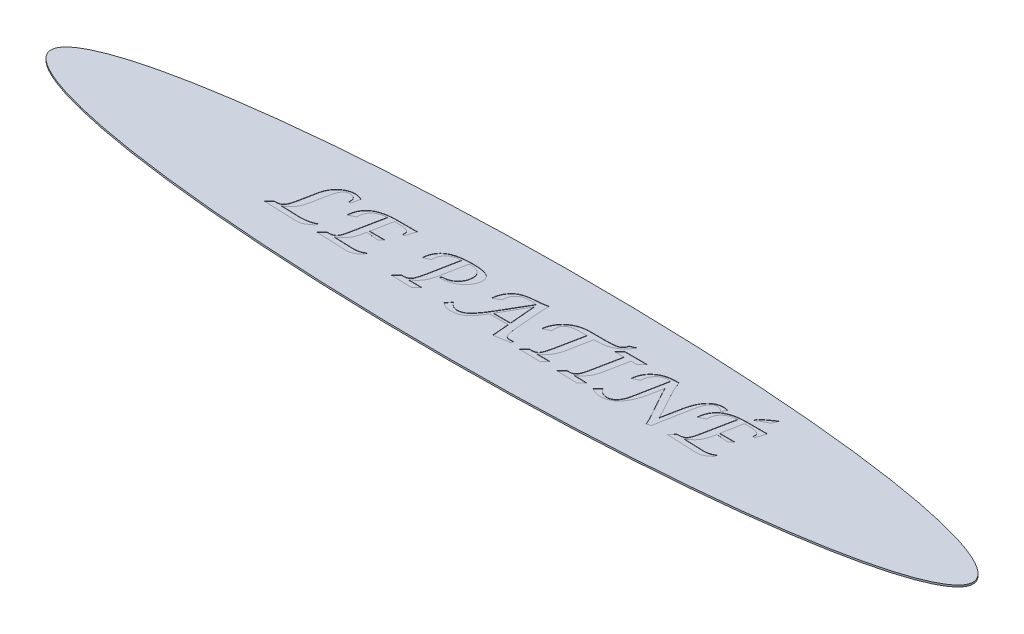
from build123d import *

# Parameters (mm, degrees)
CROQUIS1_RX             = 135
CROQUIS1_RY             = 20
SALIENTE_EXTRUIR1_DEPTH = 0.5
CORTAR_EXTRUIR2_DEPTH   = 0.1


with BuildPart() as part:
    # Croquis1 → Saliente-Extruir1 (new body)
    with BuildSketch(Plane(origin=(0, 0, 0), x_dir=(1, 0, 0), z_dir=(0, 1, 0))):
        with Locations((0, 0)):
            Ellipse(CROQUIS1_RX, CROQUIS1_RY)
    extrude(amount=SALIENTE_EXTRUIR1_DEPTH)

    # Croquis3 → Cortar-Extruir2 (cut)
    with BuildSketch(Plane(origin=(0, 0.5, 0), x_dir=(1, 0, 0), z_dir=(0, 1, 0))):
        with BuildLine():
            Line((-65.411392405, -7.111132191), (-63.984375, -5.639613203))
            Line((-63.984375, -5.639613203), (-63.399920886, -5.639613203))
            add(Edge.make_bspline(
                [(-63.399920886, -5.639613203), (-63.303900947, -5.637236771), (-63.117221766, -5.63261658), (-62.847131948, -5.599834852), (-62.596700913, -5.546924726), (-62.365912552, -5.473730418), (-62.156907433, -5.37509404), (-61.968097128, -5.254872445), (-61.796486489, -5.115429927), (-61.645744559, -4.946963441), (-61.506125109, -4.749051166), (-61.378104906, -4.512490404), (-61.24935779, -4.238829558), (-61.130395647, -3.923296605), (-61.010670602, -3.569609266), (-60.899008271, -3.17429477), (-60.793230797, -2.738452295), (-60.728083929, -2.433689909), (-60.694224684, -2.275293583)],
                knots=[0, 0, 0, 0, 0.000288021, 0.000559963, 0.000814829, 0.00105501, 0.001284604, 0.001506002, 0.001725182, 0.001945703, 0.002181948, 0.002450224, 0.002751508, 0.003088691, 0.003461148, 0.003871518, 0.004320521, 0.004806429, 0.004806429, 0.004806429, 0.004806429], degree=3))
            Line((-60.694224684, -2.275293583), (-59.667721519, 2.851288695))
            add(Edge.make_bspline(
                [(-59.667721519, 2.851288695), (-59.627267161, 3.037012829), (-59.54725351, 3.404351901), (-59.37509861, 3.936096994), (-59.171472159, 4.444476162), (-58.930105165, 4.928187917), (-58.650690184, 5.385323528), (-58.334636717, 5.818428619), (-57.979919544, 6.224883959), (-57.594112779, 6.605937947), (-57.182196709, 6.950070595), (-56.753715794, 7.253102828), (-56.308077554, 7.504965635), (-55.851693095, 7.719308113), (-55.376987269, 7.877778858), (-54.890961448, 7.995306609), (-54.390832575, 8.064440935), (-54.052818141, 8.073950173), (-53.882515823, 8.078741227)],
                knots=[0, 0, 0, 0, 0.000569937, 0.001127264, 0.001674326, 0.002211672, 0.002746942, 0.003279814, 0.003818183, 0.004363634, 0.00490493, 0.005426753, 0.005935673, 0.006438775, 0.006936954, 0.007434187, 0.007937254, 0.008448091, 0.008448091, 0.008448091, 0.008448091], degree=3))
            add(Edge.make_bspline(
                [(-53.882515823, 8.078741227), (-53.721749985, 8.071439377), (-53.383963144, 8.05609738), (-52.864124156, 7.936818748), (-52.307278396, 7.755626268), (-51.935746789, 7.586257465), (-51.740506329, 7.497253885)],
                knots=[0, 0, 0, 0, 0.000481934, 0.001012596, 0.001593334, 0.002236494, 0.002236494, 0.002236494, 0.002236494], degree=3))
            Line((-51.740506329, 7.497253885), (-52.244857595, 5.00813205))
            Line((-52.244857595, 5.00813205), (-52.888647152, 5.00813205))
            add(Edge.make_bspline(
                [(-52.888647152, 5.00813205), (-52.879568642, 5.088150387), (-52.863232465, 5.232138085), (-52.858233532, 5.37694671), (-52.856012658, 5.441280784)],
                knots=[0, 0, 0, 0, 0.000241478, 0.000434523, 0.000434523, 0.000434523, 0.000434523], degree=3))
            add(Edge.make_bspline(
                [(-52.856012658, 5.441280784), (-52.860706147, 5.58820264), (-52.869597478, 5.866530919), (-52.962190493, 6.255424091), (-53.113350494, 6.58824668), (-53.329752267, 6.861043508), (-53.609354411, 7.072030995), (-53.950905071, 7.215228007), (-54.349610684, 7.305491033), (-54.635528562, 7.314475728), (-54.787381329, 7.319247556)],
                knots=[0, 0, 0, 0, 0.000440083, 0.000833693, 0.001190717, 0.001528487, 0.001867297, 0.002229984, 0.002631585, 0.003086469, 0.003086469, 0.003086469, 0.003086469], degree=3))
            add(Edge.make_bspline(
                [(-54.787381329, 7.319247556), (-54.864657835, 7.317138052), (-55.018222737, 7.312946017), (-55.242871451, 7.274399676), (-55.457087208, 7.206762837), (-55.661538792, 7.118417153), (-55.858265269, 7.004740134), (-56.039729894, 6.85987584), (-56.218747092, 6.697110163), (-56.379779425, 6.501640208), (-56.534374584, 6.2845166), (-56.680816354, 6.043366434), (-56.813322154, 5.774486354), (-56.937767272, 5.480167133), (-57.052614513, 5.161260637), (-57.156829572, 4.81650773), (-57.251153991, 4.447129655), (-57.305151012, 4.190508393), (-57.332871835, 4.058764961)],
                knots=[0, 0, 0, 0, 0.000231712, 0.000460462, 0.000680983, 0.000904202, 0.001127578, 0.0013602, 0.0015995, 0.001852111, 0.002118014, 0.002398872, 0.002697398, 0.003016446, 0.003357109, 0.003713739, 0.004096545, 0.004500396, 0.004500396, 0.004500396, 0.004500396], degree=3))
            Line((-57.332871835, 4.058764961), (-58.258504747, -0.584233457))
            add(Edge.make_bspline(
                [(-58.258504747, -0.584233457), (-58.292898471, -0.7535984), (-58.359943319, -1.083747201), (-58.477837504, -1.56109417), (-58.61051503, -2.006151176), (-58.744164751, -2.424880304), (-58.896831163, -2.810410147), (-59.051705923, -3.168980673), (-59.222715339, -3.494279767), (-59.404237984, -3.794843203), (-59.606854625, -4.074576159), (-59.830813999, -4.343248619), (-60.080088206, -4.60336819), (-60.353821706, -4.856888021), (-60.655425792, -5.099799735), (-60.981437042, -5.337557953), (-61.335231178, -5.565333797), (-61.582676898, -5.708838614), (-61.708860759, -5.782018267)],
                knots=[0, 0, 0, 0, 0.000518439, 0.00101061, 0.001474376, 0.00191157, 0.002328631, 0.002717822, 0.003082747, 0.003430264, 0.003770319, 0.004117888, 0.004478811, 0.004850416, 0.005236382, 0.005639907, 0.006060414, 0.006497991, 0.006497991, 0.006497991, 0.006497991], degree=3))
            Line((-61.708860759, -5.782018267), (-56.086827532, -5.971891684))
            add(Edge.make_bspline(
                [(-56.086827532, -5.971891684), (-55.887971476, -5.969089823), (-55.494699148, -5.963548658), (-54.914301421, -5.918154108), (-54.351698654, -5.844352854), (-53.808631487, -5.741132748), (-53.283670301, -5.606729736), (-52.777080884, -5.444234094), (-52.287754671, -5.252207658), (-51.975876218, -5.098865286), (-51.820609177, -5.022524596)],
                knots=[0, 0, 0, 0, 0.000596506, 0.001179693, 0.001745297, 0.002298057, 0.002837006, 0.00336992, 0.003893293, 0.004412172, 0.004412172, 0.004412172, 0.004412172], degree=3))
            Line((-51.820609177, -5.022524596), (-51.971914557, -5.782018267))
            add(Edge.make_bspline(
                [(-51.971914557, -5.782018267), (-52.085315144, -5.869475741), (-52.303968469, -6.038106856), (-52.624355542, -6.274212768), (-52.9202023, -6.489494573), (-53.196847373, -6.676593474), (-53.451549976, -6.839013756), (-53.682264732, -6.980727276), (-53.893214207, -7.09261685), (-54.148454038, -7.216963911), (-54.484928401, -7.331173063), (-54.928206465, -7.423176323), (-55.427541375, -7.483744789), (-55.780066683, -7.488422565), (-55.965189873, -7.490879026)],
                knots=[0, 0, 0, 0, 0.000429609, 0.00082835, 0.001193926, 0.001527183, 0.001830041, 0.002100212, 0.002339125, 0.002546141, 0.002951472, 0.003400701, 0.003902638, 0.00445771, 0.00445771, 0.00445771, 0.00445771], degree=3))
            Line((-55.965189873, -7.490879026), (-65.411392405, -7.111132191))
        make_face()
        with BuildLine():
            Line((-49.841772152, -7.301005608), (-48.358386076, -5.793885355))
            Line((-48.358386076, -5.793885355), (-48.189280063, -5.793885355))
            add(Edge.make_bspline(
                [(-48.189280063, -5.793885355), (-48.066589336, -5.792571706), (-47.831687619, -5.790056615), (-47.49356723, -5.760179244), (-47.186168152, -5.71051009), (-46.906671513, -5.643017038), (-46.657711735, -5.555135576), (-46.437231245, -5.447301059), (-46.245157368, -5.32115011), (-46.081521014, -5.165082067), (-45.935133438, -4.977130256), (-45.799774763, -4.746015517), (-45.670898067, -4.467854302), (-45.54322036, -4.14418666), (-45.424165493, -3.772664823), (-45.304185355, -3.355686574), (-45.192890332, -2.891145907), (-45.126540853, -2.564277098), (-45.091969937, -2.393964469)],
                knots=[0, 0, 0, 0, 0.000367987, 0.000704543, 0.001017182, 0.001301404, 0.00156603, 0.001807508, 0.002036257, 0.002252425, 0.002482708, 0.00274881, 0.003054041, 0.003401673, 0.003791959, 0.004223927, 0.00470316, 0.005224502, 0.005224502, 0.005224502, 0.005224502], degree=3))
            Line((-45.091969937, -2.393964469), (-43.267405063, 6.749627303))
            add(Edge.make_bspline(
                [(-43.267405063, 6.749627303), (-43.435673845, 6.746401637), (-43.764196151, 6.740103956), (-44.244399109, 6.685347553), (-44.700171351, 6.597300709), (-45.132075294, 6.472184836), (-45.540985246, 6.31344711), (-45.921573173, 6.111668304), (-46.280212059, 5.881049051), (-46.60889738, 5.612816698), (-46.907212962, 5.318848854), (-47.168930358, 4.999699327), (-47.383868062, 4.65549753), (-47.569635171, 4.294302206), (-47.707297777, 3.907821766), (-47.805295542, 3.500024837), (-47.865765459, 3.071644118), (-47.873716156, 2.77830769), (-47.877768987, 2.628780784)],
                knots=[0, 0, 0, 0, 0.000504665, 0.000985292, 0.001447851, 0.001895716, 0.002332598, 0.002761222, 0.003185833, 0.003609791, 0.004031459, 0.004440594, 0.004844707, 0.005246724, 0.005656837, 0.006072026, 0.006503342, 0.006951805, 0.006951805, 0.006951805, 0.006951805], degree=3))
            Line((-47.877768987, 2.628780784), (-47.877768987, 2.400339328))
            Line((-47.877768987, 2.400339328), (-49.821004747, 1.427238062))
            add(Edge.make_bspline(
                [(-49.821004747, 1.427238062), (-49.7952135, 1.678161891), (-49.744991379, 2.166774442), (-49.590522064, 2.869637939), (-49.38494448, 3.525356823), (-49.115030087, 4.128747248), (-48.785282721, 4.681345033), (-48.397701432, 5.183274905), (-47.948981558, 5.634366668), (-47.439291226, 6.034679706), (-46.868345581, 6.385392376), (-46.234814571, 6.688871118), (-45.536386789, 6.941849589), (-44.77598735, 7.153201235), (-43.94971224, 7.308933916), (-43.061740595, 7.42922419), (-42.108401654, 7.49530896), (-41.451834945, 7.504424201), (-41.113528481, 7.509120974)],
                knots=[0, 0, 0, 0, 0.000756207, 0.001472527, 0.002154633, 0.002814632, 0.003450629, 0.004080843, 0.004712292, 0.005354487, 0.006020558, 0.006718526, 0.007458151, 0.008246314, 0.00908358, 0.009978547, 0.010933322, 0.011948236, 0.011948236, 0.011948236, 0.011948236], degree=3))
            Line((-41.113528481, 7.509120974), (-35.221518987, 7.509120974))
            Line((-35.221518987, 7.509120974), (-36.114517405, 4.631351986))
            Line((-36.114517405, 4.631351986), (-36.743473101, 4.631351986))
            add(Edge.make_bspline(
                [(-36.743473101, 4.631351986), (-36.720521546, 4.755607113), (-36.677201989, 4.990130521), (-36.667793799, 5.228387022), (-36.663370253, 5.340410531)],
                knots=[0, 0, 0, 0, 0.000378493, 0.000714381, 0.000714381, 0.000714381, 0.000714381], degree=3))
            add(Edge.make_bspline(
                [(-36.663370253, 5.340410531), (-36.666356126, 5.404886678), (-36.672163887, 5.53029795), (-36.713270473, 5.710890762), (-36.786818947, 5.873649369), (-36.885742338, 6.023521663), (-37.019177303, 6.151942235), (-37.174832336, 6.270815335), (-37.36239494, 6.367537369), (-37.579486242, 6.450824874), (-37.833911454, 6.521965113), (-38.13143403, 6.582760109), (-38.474902538, 6.636141161), (-38.865310461, 6.674871891), (-39.301286694, 6.712073168), (-39.784200072, 6.734600318), (-40.313442067, 6.744943849), (-40.681364636, 6.748022121), (-40.873219937, 6.749627303)],
                knots=[0, 0, 0, 0, 0.00019341, 0.000376198, 0.000551514, 0.000726779, 0.000911388, 0.001104228, 0.0013126, 0.001541792, 0.001800973, 0.002104121, 0.002452385, 0.002843246, 0.003280812, 0.003764978, 0.004293197, 0.004868781, 0.004868781, 0.004868781, 0.004868781], degree=3))
            Line((-40.873219937, 6.749627303), (-41.184731013, 6.749627303))
            Line((-41.184731013, 6.749627303), (-42.347705696, 0.673677936))
            Line((-42.347705696, 0.673677936), (-37.876780063, 0.673677936))
            Line((-37.876780063, 0.673677936), (-38.900316456, -0.364692317))
            add(Edge.make_bspline(
                [(-38.900316456, -0.364692317), (-39.08225535, -0.342747119), (-39.430189054, -0.300779873), (-39.930499289, -0.243454679), (-40.385691963, -0.197683358), (-40.794711042, -0.153971771), (-41.158800961, -0.124143139), (-41.477389149, -0.104961757), (-41.751181498, -0.086632105), (-41.918488753, -0.086071133), (-41.99465981, -0.085815735)],
                knots=[0, 0, 0, 0, 0.000549774, 0.001051369, 0.001510711, 0.001922227, 0.002285388, 0.002606471, 0.002879817, 0.003108278, 0.003108278, 0.003108278, 0.003108278], degree=3))
            Line((-41.99465981, -0.085815735), (-42.496044304, -0.085815735))
            Line((-42.496044304, -0.085815735), (-42.706685127, -1.12715276))
            add(Edge.make_bspline(
                [(-42.706685127, -1.12715276), (-42.7357891, -1.269922261), (-42.792690032, -1.549049705), (-42.90235544, -1.952664757), (-43.015936881, -2.335632387), (-43.143587971, -2.695134193), (-43.283218076, -3.031859219), (-43.434365873, -3.345495989), (-43.594372115, -3.639176578), (-43.770993654, -3.911858369), (-43.96939246, -4.17179544), (-44.187625613, -4.429847991), (-44.435934178, -4.684828661), (-44.709492386, -4.941048238), (-45.0114453, -5.194372407), (-45.340761445, -5.447678767), (-45.694721004, -5.702951942), (-45.945657749, -5.865195852), (-46.073971519, -5.948157507)],
                knots=[0, 0, 0, 0, 0.000437003, 0.00085438, 0.001254202, 0.001635175, 0.001998262, 0.002347246, 0.002679206, 0.003000961, 0.003320781, 0.00365963, 0.004014218, 0.004387843, 0.00478366, 0.005196084, 0.005634083, 0.006092408, 0.006092408, 0.006092408, 0.006092408], degree=3))
            Line((-46.073971519, -5.948157507), (-41.264833861, -6.132097381))
            Line((-41.264833861, -6.132097381), (-40.211629747, -6.161765102))
            add(Edge.make_bspline(
                [(-40.211629747, -6.161765102), (-40.077018344, -6.15889603), (-39.808053803, -6.15316339), (-39.408310917, -6.107457869), (-39.01465443, -6.033100049), (-38.628627848, -5.929513707), (-38.249335267, -5.79417776), (-37.876136612, -5.631615688), (-37.509047125, -5.438348391), (-37.274485332, -5.288290571), (-37.15585443, -5.212398014)],
                knots=[0, 0, 0, 0, 0.000403754, 0.000806733, 0.001205308, 0.001604722, 0.002004455, 0.00241233, 0.002825063, 0.003247409, 0.003247409, 0.003247409, 0.003247409], degree=3))
            Line((-37.15585443, -5.212398014), (-37.316060127, -5.971891684))
            add(Edge.make_bspline(
                [(-37.316060127, -5.971891684), (-37.460524559, -6.107555889), (-37.740478859, -6.370456429), (-38.177436071, -6.716421566), (-38.604713757, -7.012381942), (-39.025110437, -7.25648344), (-39.440779699, -7.444308192), (-39.850101693, -7.579788653), (-40.253616408, -7.664678925), (-40.521765921, -7.67545251), (-40.653678797, -7.680752444)],
                knots=[0, 0, 0, 0, 0.00059431, 0.001151701, 0.001670139, 0.002152566, 0.002608031, 0.003035843, 0.003444289, 0.003839772, 0.003839772, 0.003839772, 0.003839772], degree=3))
            Line((-40.653678797, -7.680752444), (-41.113528481, -7.671852127))
            Line((-41.113528481, -7.671852127), (-49.841772152, -7.301005608))
        make_face()
        with BuildLine():
            Line((-28.006329114, -7.301005608), (-26.534810127, -5.782018267))
            Line((-26.534810127, -5.782018267), (-26.347903481, -5.782018267))
            Line((-26.347903481, -5.782018267), (-25.920688291, -5.77311795))
            add(Edge.make_bspline(
                [(-25.920688291, -5.77311795), (-25.826555496, -5.771414478), (-25.64435771, -5.768117338), (-25.381633574, -5.726386619), (-25.136548137, -5.670278639), (-24.912702599, -5.582825913), (-24.707288697, -5.472543387), (-24.524129178, -5.334933662), (-24.357079354, -5.176549111), (-24.212672217, -4.985456026), (-24.075531173, -4.759360586), (-23.948050272, -4.485676357), (-23.821134115, -4.163144193), (-23.693596106, -3.792166792), (-23.570774774, -3.369758838), (-23.446341019, -2.899075844), (-23.324183821, -2.377796019), (-23.250542485, -2.012461199), (-23.212025316, -1.821377444)],
                knots=[0, 0, 0, 0, 0.000282093, 0.000546002, 0.000796409, 0.001034972, 0.001264643, 0.001493681, 0.001720285, 0.001952907, 0.002209854, 0.002512406, 0.00285728, 0.003249456, 0.003688778, 0.004176675, 0.004709919, 0.005294674, 0.005294674, 0.005294674, 0.005294674], degree=3))
            Line((-23.212025316, -1.821377444), (-21.532832278, 6.749627303))
            add(Edge.make_bspline(
                [(-21.532832278, 6.749627303), (-21.698117322, 6.746152484), (-22.02058098, 6.739373268), (-22.492863118, 6.688080317), (-22.940998533, 6.603856901), (-23.365129064, 6.480052406), (-23.766935238, 6.327953542), (-24.143811647, 6.135352263), (-24.497075506, 5.910510157), (-24.822616535, 5.652521837), (-25.11748487, 5.368631821), (-25.372413264, 5.058873443), (-25.592302442, 4.729948839), (-25.771045503, 4.378609984), (-25.907606622, 4.004692489), (-26.005178287, 3.610849838), (-26.065986085, 3.196325908), (-26.07389408, 2.912812841), (-26.077927215, 2.768219075)],
                knots=[0, 0, 0, 0, 0.000495771, 0.000967226, 0.001423396, 0.001861886, 0.002291085, 0.002710356, 0.00312926, 0.003545338, 0.003954462, 0.004354834, 0.004746504, 0.00513924, 0.0055344, 0.005938067, 0.006354695, 0.006788341, 0.006788341, 0.006788341, 0.006788341], degree=3))
            Line((-26.077927215, 2.768219075), (-26.069026899, 2.548677936))
            Line((-26.069026899, 2.548677936), (-27.997428797, 1.611177936))
            add(Edge.make_bspline(
                [(-27.997428797, 1.611177936), (-27.969629807, 1.860153976), (-27.91548491, 2.345091801), (-27.755894494, 3.041372051), (-27.543426074, 3.686133461), (-27.273594004, 4.279053121), (-26.940996738, 4.816841303), (-26.553906662, 5.305306366), (-26.104868455, 5.73766668), (-25.596514248, 6.118773247), (-25.023286423, 6.449644607), (-24.380694312, 6.732977614), (-23.668962468, 6.975596172), (-22.886200884, 7.173540173), (-22.030947805, 7.321927399), (-21.105823369, 7.429255744), (-20.109874011, 7.499936763), (-19.422596314, 7.505991948), (-19.06744462, 7.509120974)],
                knots=[0, 0, 0, 0, 0.000751068, 0.001462877, 0.002138364, 0.002784855, 0.003412248, 0.004030797, 0.004649744, 0.00527692, 0.005932315, 0.006630868, 0.007380499, 0.008185682, 0.009050484, 0.009982603, 0.010978812, 0.012044085, 0.012044085, 0.012044085, 0.012044085], degree=3))
            add(Edge.make_bspline(
                [(-19.06744462, 7.509120974), (-18.812284029, 7.506413582), (-18.321563366, 7.50120677), (-17.613839806, 7.473709952), (-16.962794251, 7.419482462), (-16.368032105, 7.349211764), (-15.830947053, 7.249159922), (-15.348846664, 7.137219741), (-14.923559376, 6.998996523), (-14.552567625, 6.837617438), (-14.229346165, 6.65396599), (-13.953808328, 6.437794926), (-13.718298132, 6.195477708), (-13.52621944, 5.922068262), (-13.377554846, 5.619474451), (-13.269556977, 5.289210034), (-13.207464119, 4.93036783), (-13.200029122, 4.6820291), (-13.196202532, 4.55421591)],
                knots=[0, 0, 0, 0, 0.000765519, 0.001472234, 0.002124148, 0.002725064, 0.003267983, 0.003762332, 0.004208907, 0.004607439, 0.004974324, 0.005320916, 0.00565453, 0.005984589, 0.00631894, 0.006662318, 0.007023741, 0.007407018, 0.007407018, 0.007407018, 0.007407018], degree=3))
            add(Edge.make_bspline(
                [(-13.196202532, 4.55421591), (-13.198993684, 4.447240901), (-13.204599767, 4.232379587), (-13.252402395, 3.911178748), (-13.321931401, 3.587744813), (-13.428872116, 3.264740276), (-13.558145925, 2.93755943), (-13.720577913, 2.610222077), (-13.910113872, 2.280771267), (-14.129075076, 1.955190646), (-14.366737954, 1.635604522), (-14.625972818, 1.334797542), (-14.894989886, 1.047181655), (-15.183387324, 0.784622689), (-15.485642124, 0.539148293), (-15.801867126, 0.311165234), (-16.134361857, 0.101987263), (-16.366808482, -0.019135967), (-16.483386076, -0.079882191)],
                knots=[0, 0, 0, 0, 0.000320755, 0.000644242, 0.000972469, 0.001312109, 0.001663594, 0.002027141, 0.00240727, 0.002803054, 0.003203568, 0.003601304, 0.003993737, 0.004384293, 0.004770259, 0.005161355, 0.005553194, 0.005947429, 0.005947429, 0.005947429, 0.005947429], degree=3))
            add(Edge.make_bspline(
                [(-16.483386076, -0.079882191), (-16.621011741, -0.145089051), (-16.898441246, -0.276534787), (-17.331815215, -0.4394875), (-17.777153558, -0.584950881), (-18.239065913, -0.69553847), (-18.714318282, -0.784901375), (-19.20441844, -0.850243959), (-19.709585179, -0.889751365), (-20.051352341, -0.893729352), (-20.224485759, -0.895744533)],
                knots=[0, 0, 0, 0, 0.00045669, 0.000920608, 0.001387854, 0.001861321, 0.002344277, 0.002838126, 0.00334395, 0.003863271, 0.003863271, 0.003863271, 0.003863271], degree=3))
            Line((-20.224485759, -0.895744533), (-20.494462025, -0.895744533))
            Line((-20.494462025, -0.895744533), (-20.120648734, -0.326124279))
            Line((-20.120648734, -0.326124279), (-19.942642405, -0.326124279))
            add(Edge.make_bspline(
                [(-19.942642405, -0.326124279), (-19.787173722, -0.322123377), (-19.482002293, -0.314269955), (-19.034233103, -0.252712163), (-18.605152677, -0.156841697), (-18.196381419, -0.015130278), (-17.804885536, 0.162895915), (-17.433597847, 0.38364689), (-17.0818619, 0.643106649), (-16.754577474, 0.938787423), (-16.45584698, 1.263061656), (-16.194378657, 1.611436785), (-15.969185719, 1.977757616), (-15.787895946, 2.365150589), (-15.648554123, 2.771317708), (-15.546624992, 3.195235187), (-15.486895562, 3.639734466), (-15.478805431, 3.942881113), (-15.474683544, 4.097332999)],
                knots=[0, 0, 0, 0, 0.000466246, 0.0009152, 0.00135349, 0.001783191, 0.002210663, 0.002641622, 0.003076565, 0.003519808, 0.003962851, 0.004397187, 0.004824587, 0.005250616, 0.005677512, 0.006110701, 0.006556715, 0.007019997, 0.007019997, 0.007019997, 0.007019997], degree=3))
            add(Edge.make_bspline(
                [(-15.474683544, 4.097332999), (-15.477102871, 4.212229585), (-15.481817761, 4.436145059), (-15.530740752, 4.760246062), (-15.607082053, 5.061902456), (-15.714060037, 5.341753107), (-15.855316987, 5.598004109), (-16.024375758, 5.835325392), (-16.229411426, 6.046381544), (-16.461643474, 6.237484501), (-16.725618458, 6.404861405), (-17.022112923, 6.546721403), (-17.348394512, 6.666662934), (-17.703956519, 6.769040627), (-18.091353609, 6.843998282), (-18.509275223, 6.900531922), (-18.95817273, 6.932326219), (-19.267159412, 6.937060483), (-19.426424051, 6.939500721)],
                knots=[0, 0, 0, 0, 0.000344465, 0.000671309, 0.000980722, 0.001276582, 0.001567341, 0.001856354, 0.002148019, 0.002447355, 0.002756811, 0.003083223, 0.0034315, 0.003798673, 0.004191991, 0.004614087, 0.005063257, 0.005541054, 0.005541054, 0.005541054, 0.005541054], degree=3))
            Line((-19.426424051, 6.939500721), (-21.016613924, -1.156820482))
            add(Edge.make_bspline(
                [(-21.016613924, -1.156820482), (-21.071806858, -1.40545089), (-21.180656094, -1.895789566), (-21.43102481, -2.599171013), (-21.742922335, -3.261783175), (-22.121713117, -3.882707927), (-22.567790555, -4.460192019), (-23.073522804, -5.000908444), (-23.649994639, -5.496387003), (-24.073438144, -5.785944075), (-24.288963608, -5.933323646)],
                knots=[0, 0, 0, 0, 0.000763453, 0.00150565, 0.002234226, 0.002957249, 0.003682969, 0.004419667, 0.005174913, 0.005957792, 0.005957792, 0.005957792, 0.005957792], degree=3))
            Line((-24.288963608, -5.933323646), (-20.485561709, -5.971891684))
            Line((-20.485561709, -5.971891684), (-21.850276899, -7.490879026))
            Line((-21.850276899, -7.490879026), (-28.006329114, -7.301005608))
        make_face()
        with BuildLine():
            Line((-13.386075949, -6.541511938), (-12.056962025, -5.022524596))
            add(Edge.make_bspline(
                [(-12.056962025, -5.022524596), (-11.977570155, -5.143176153), (-11.823341857, -5.377556377), (-11.553824372, -5.686898169), (-11.268265542, -5.951154763), (-10.963357492, -6.167227143), (-10.640042966, -6.335521131), (-10.297521317, -6.455169912), (-9.935863724, -6.52841537), (-9.687843766, -6.537101421), (-9.561906646, -6.541511938)],
                knots=[0, 0, 0, 0, 0.000432874, 0.000840911, 0.001227275, 0.001597682, 0.001958606, 0.002317033, 0.002683006, 0.003060533, 0.003060533, 0.003060533, 0.003060533], degree=3))
            add(Edge.make_bspline(
                [(-9.561906646, -6.541511938), (-9.439989457, -6.538683995), (-9.196654543, -6.533039695), (-8.835394372, -6.46867514), (-8.478725111, -6.376017708), (-8.128570486, -6.239465054), (-7.783711307, -6.067094008), (-7.444581103, -5.854802871), (-7.111484283, -5.604298638), (-6.781579021, -5.311332237), (-6.445616238, -4.971483588), (-6.099615912, -4.57413838), (-5.733794348, -4.120060725), (-5.357728688, -3.603567383), (-4.960805841, -3.031632988), (-4.550011695, -2.399986558), (-4.122501141, -1.708642735), (-3.839859717, -1.223747671), (-3.693631329, -0.972880608)],
                knots=[0, 0, 0, 0, 0.000365347, 0.000729197, 0.001097651, 0.001469552, 0.001854318, 0.002252761, 0.002668109, 0.003103215, 0.00357523, 0.004100759, 0.004683169, 0.005324019, 0.006016956, 0.006771531, 0.007584151, 0.008455241, 0.008455241, 0.008455241, 0.008455241], degree=3))
            Line((-3.693631329, -0.972880608), (0.623022152, 6.467783948))
            add(Edge.make_bspline(
                [(0.623022152, 6.467783948), (0.448058791, 6.487308743), (0.111322248, 6.524886392), (-0.375252773, 6.567272698), (-0.823521351, 6.591762584), (-1.109547497, 6.596202917), (-1.246044304, 6.598321923)],
                knots=[0, 0, 0, 0, 0.000528135, 0.001016456, 0.001465067, 0.001874578, 0.001874578, 0.001874578, 0.001874578], degree=3))
            add(Edge.make_bspline(
                [(-1.246044304, 6.598321923), (-1.41523857, 6.594494893), (-1.744418951, 6.587049114), (-2.223993723, 6.541211838), (-2.672826658, 6.456689162), (-3.094138978, 6.346372793), (-3.4845721, 6.197173125), (-3.844791213, 6.015308879), (-4.178304178, 5.804631006), (-4.477538685, 5.556949163), (-4.746303328, 5.281835867), (-4.975270085, 4.974934609), (-5.174409085, 4.64468375), (-5.330169269, 4.281299453), (-5.455405614, 3.892084528), (-5.543211685, 3.474531496), (-5.597825737, 3.029759211), (-5.604014577, 2.723883079), (-5.607199367, 2.566478569)],
                knots=[0, 0, 0, 0, 0.00050763, 0.000987633, 0.001443253, 0.001876493, 0.002292487, 0.002694504, 0.00308542, 0.003473263, 0.003857216, 0.004236371, 0.004619499, 0.005011405, 0.005419538, 0.005844315, 0.006289578, 0.006761631, 0.006761631, 0.006761631, 0.006761631], degree=3))
            Line((-5.607199367, 2.566478569), (-7.568235759, 1.596344075))
            add(Edge.make_bspline(
                [(-7.568235759, 1.596344075), (-7.54982834, 1.749815783), (-7.513722375, 2.050848974), (-7.437055781, 2.492055753), (-7.336949942, 2.912214085), (-7.213344481, 3.311500911), (-7.076373697, 3.69284928), (-6.911640994, 4.051807549), (-6.729198287, 4.392169915), (-6.587949586, 4.603720839), (-6.517998418, 4.708488062)],
                knots=[0, 0, 0, 0, 0.000463662, 0.000909468, 0.001342658, 0.001758398, 0.002162935, 0.002557259, 0.002942254, 0.003319979, 0.003319979, 0.003319979, 0.003319979], degree=3))
            add(Edge.make_bspline(
                [(-6.517998418, 4.708488062), (-6.438116882, 4.819180099), (-6.280935204, 5.03698713), (-6.0276062, 5.343374212), (-5.764479386, 5.626309), (-5.487169245, 5.881163412), (-5.201789087, 6.114353371), (-4.905557738, 6.322044589), (-4.597919325, 6.504214578), (-4.275503239, 6.663541537), (-3.929645159, 6.804734427), (-3.551257329, 6.92778825), (-3.137433589, 7.040791967), (-2.687638959, 7.139826109), (-2.202106102, 7.230173299), (-1.679159786, 7.30215014), (-1.120378247, 7.365607336), (-0.734894366, 7.393784486), (-0.536985759, 7.408250721)],
                knots=[0, 0, 0, 0, 0.000409425, 0.00080562, 0.001191825, 0.001567622, 0.001934592, 0.002296733, 0.002651879, 0.003006132, 0.003374705, 0.003771554, 0.004199068, 0.004661161, 0.005152867, 0.005680261, 0.006244431, 0.006839681, 0.006839681, 0.006839681, 0.006839681], degree=3))
            add(Edge.make_bspline(
                [(-0.536985759, 7.408250721), (-0.445012477, 7.414125942), (-0.24025497, 7.427205781), (0.098094484, 7.450258014), (0.498296761, 7.484945265), (0.786169128, 7.50647923), (0.940466772, 7.51802129)],
                knots=[0, 0, 0, 0, 0.000276483, 0.000615527, 0.001017369, 0.001481553, 0.001481553, 0.001481553, 0.001481553], degree=3))
            Line((0.940466772, 7.51802129), (2.981606013, 7.888867809))
            Line((2.981606013, 7.888867809), (3.112143987, 4.551249138))
            Line((3.112143987, 4.551249138), (3.690664557, -2.373197064))
            add(Edge.make_bspline(
                [(3.690664557, -2.373197064), (3.708031573, -2.56607434), (3.74118594, -2.934285219), (3.795452341, -3.460986509), (3.861722046, -3.935471481), (3.929870328, -4.359793203), (3.997511419, -4.734094326), (4.079092592, -5.055160333), (4.159241515, -5.325959659), (4.248513816, -5.549847834), (4.35338978, -5.734598446), (4.470867293, -5.89339105), (4.609895952, -6.025997364), (4.767395489, -6.13431087), (4.941885369, -6.220659385), (5.136275987, -6.279937581), (5.347753699, -6.315754251), (5.495302141, -6.319851927), (5.571598101, -6.321970798)],
                knots=[0, 0, 0, 0, 0.00058098, 0.001109115, 0.001588265, 0.002017966, 0.0023985, 0.002728773, 0.00301124, 0.00324539, 0.003449989, 0.003646984, 0.003835835, 0.00402347, 0.004218511, 0.00441744, 0.004631068, 0.004859817, 0.004859817, 0.004859817, 0.004859817], degree=3))
            add(Edge.make_bspline(
                [(5.571598101, -6.321970798), (5.590389528, -6.322103843), (5.63590287, -6.322426082), (5.717017235, -6.318824886), (5.823719407, -6.312050221), (5.957344091, -6.307433885), (6.116439442, -6.297159594), (6.301480967, -6.289446528), (6.512103259, -6.277100981), (6.661396829, -6.267645658), (6.740506329, -6.262635355)],
                knots=[0, 0, 0, 0, 5.6369e-05, 0.000136526, 0.000243495, 0.000377131, 0.000537584, 0.000721739, 0.000932714, 0.001170519, 0.001170519, 0.001170519, 0.001170519], degree=3))
            Line((6.740506329, -6.262635355), (6.740506329, -6.921258773))
            Line((6.740506329, -6.921258773), (2.020371835, -7.680752444))
            Line((2.020371835, -7.680752444), (1.610957278, -2.744043583))
            Line((1.610957278, -2.744043583), (-3.839003165, -2.744043583))
            add(Edge.make_bspline(
                [(-3.839003165, -2.744043583), (-3.968140657, -2.965416382), (-4.218245851, -3.394156991), (-4.604890847, -4.003880119), (-4.986296222, -4.561442498), (-5.363481379, -5.067175508), (-5.734012544, -5.522132956), (-6.098653344, -5.927929299), (-6.459659701, -6.281547108), (-6.819306861, -6.58694943), (-7.186933632, -6.844944901), (-7.56532589, -7.069287493), (-7.960197273, -7.259282919), (-8.372806192, -7.415539754), (-8.803494645, -7.532269414), (-9.250461708, -7.619523271), (-9.714031598, -7.669946671), (-10.028560234, -7.677119035), (-10.18789557, -7.680752444)],
                knots=[0, 0, 0, 0, 0.000768806, 0.001488975, 0.002165405, 0.002794955, 0.003381101, 0.003925122, 0.004430737, 0.004896066, 0.005338901, 0.005776477, 0.006214365, 0.006651881, 0.007098131, 0.007551388, 0.008016944, 0.008494926, 0.008494926, 0.008494926, 0.008494926], degree=3))
            add(Edge.make_bspline(
                [(-10.18789557, -7.680752444), (-10.339364215, -7.677439215), (-10.638317849, -7.670899896), (-11.078980438, -7.615771293), (-11.504086285, -7.527752494), (-11.913094221, -7.402146888), (-12.306470976, -7.241515284), (-12.684286707, -7.044216998), (-13.048492993, -6.814097695), (-13.273030807, -6.632791711), (-13.386075949, -6.541511938)],
                knots=[0, 0, 0, 0, 0.000454265, 0.000896583, 0.001330067, 0.001755186, 0.002178302, 0.002602923, 0.003032522, 0.003468102, 0.003468102, 0.003468102, 0.003468102], degree=3))
        make_face()
        Polygon((-3.408821203, -1.984549912), (1.539754747, -1.984549912), (0.901898734, 5.527317176), align=None, mode=Mode.SUBTRACT)
        with BuildLine():
            Line((9.440268987, -7.301005608), (10.926621835, -5.782018267))
            Line((10.926621835, -5.782018267), (11.077927215, -5.81465276))
            add(Edge.make_bspline(
                [(11.077927215, -5.81465276), (11.10459446, -5.818136204), (11.172502051, -5.827006723), (11.296603048, -5.824869726), (11.463496783, -5.835232954), (11.589173879, -5.833449925), (11.659414557, -5.832453393)],
                knots=[0, 0, 0, 0, 8.0596e-05, 0.000205236, 0.000371481, 0.000582122, 0.000582122, 0.000582122, 0.000582122], degree=3))
            add(Edge.make_bspline(
                [(11.659414557, -5.832453393), (11.749598949, -5.83071648), (11.924918816, -5.827339895), (12.177739074, -5.785676818), (12.414234401, -5.729894197), (12.630158047, -5.640521722), (12.831270938, -5.533015557), (13.008951917, -5.392241919), (13.175718788, -5.236128379), (13.32003493, -5.044777465), (13.455612018, -4.819960846), (13.585115592, -4.551281553), (13.710184457, -4.235898659), (13.840093505, -3.875973815), (13.957893871, -3.46637399), (14.079431897, -3.012380394), (14.203235333, -2.512728735), (14.274492292, -2.161866884), (14.311708861, -1.978616368)],
                knots=[0, 0, 0, 0, 0.000270237, 0.000525345, 0.000767114, 0.000997397, 0.001224467, 0.001448768, 0.001675371, 0.001907994, 0.002164941, 0.002462152, 0.00280152, 0.003182493, 0.003609595, 0.004079526, 0.004592572, 0.005153488, 0.005153488, 0.005153488, 0.005153488], degree=3))
            Line((14.311708861, -1.978616368), (15.907832278, 5.990133632))
            Line((15.907832278, 5.990133632), (13.365308544, 5.990133632))
            add(Edge.make_bspline(
                [(13.365308544, 5.990133632), (13.208980052, 5.988055877), (12.90676963, 5.984039212), (12.467918463, 5.947526037), (12.059217489, 5.89020746), (11.680894914, 5.806053), (11.331062688, 5.704572326), (11.012375929, 5.573240273), (10.723812942, 5.419538046), (10.464222141, 5.242474011), (10.234764277, 5.041224354), (10.038306441, 4.813234596), (9.869215416, 4.564230664), (9.732915552, 4.290729667), (9.629977895, 3.992978697), (9.551267459, 3.673597001), (9.507934047, 3.329144082), (9.502427879, 3.091710568), (9.49960443, 2.969959581)],
                knots=[0, 0, 0, 0, 0.0004689, 0.000906466, 0.001320158, 0.001705987, 0.002068298, 0.002411534, 0.002738054, 0.003047468, 0.003352237, 0.003650866, 0.003947914, 0.004253074, 0.004564599, 0.004891281, 0.005238292, 0.005603506, 0.005603506, 0.005603506, 0.005603506], degree=3))
            add(Edge.make_bspline(
                [(9.49960443, 2.969959581), (9.500820017, 2.906626859), (9.503388292, 2.77281837), (9.523579609, 2.56222898), (9.548939789, 2.330437089), (9.574990636, 2.169818129), (9.588607595, 2.08586148)],
                knots=[0, 0, 0, 0, 0.000189966, 0.000401358, 0.000634301, 0.000889409, 0.000889409, 0.000889409, 0.000889409], degree=3))
            Line((9.588607595, 2.08586148), (7.5, 1.121660531))
            add(Edge.make_bspline(
                [(7.5, 1.121660531), (7.540471827, 1.361810065), (7.619792843, 1.832480811), (7.80568708, 2.514080769), (8.045979754, 3.156686684), (8.340586161, 3.762002899), (8.689022478, 4.32876939), (9.092752869, 4.856359863), (9.547036991, 5.34798186), (10.05586738, 5.794647105), (10.606180776, 6.197993502), (11.196339395, 6.549526042), (11.821539457, 6.846030092), (12.480095207, 7.091616514), (13.174315524, 7.27584421), (13.900726523, 7.413852004), (14.662935399, 7.494282254), (15.182762229, 7.50410786), (15.447982595, 7.509120974)],
                knots=[0, 0, 0, 0, 0.000730266, 0.001431253, 0.002115652, 0.00278571, 0.003447699, 0.004108124, 0.004775707, 0.005452508, 0.006136103, 0.00681993, 0.007509983, 0.008209317, 0.008925398, 0.009662042, 0.010425749, 0.011221292, 0.011221292, 0.011221292, 0.011221292], degree=3))
            Line((15.447982595, 7.509120974), (19.705300633, 7.509120974))
            add(Edge.make_bspline(
                [(19.705300633, 7.509120974), (19.935731984, 7.51014819), (20.375902423, 7.51211038), (21.006017724, 7.52982136), (21.57486115, 7.558679521), (22.08263099, 7.598705564), (22.528721998, 7.652741251), (22.915898356, 7.711641816), (23.242394655, 7.787574296), (23.517160596, 7.876721384), (23.750447998, 7.990011358), (23.95823516, 8.128431187), (24.146768957, 8.29549767), (24.312663355, 8.494145791), (24.462548376, 8.71864325), (24.592245061, 8.972925239), (24.706506715, 9.25541502), (24.761777931, 9.457610639), (24.790348101, 9.562127303)],
                knots=[0, 0, 0, 0, 0.000691283, 0.001320491, 0.001890883, 0.002399899, 0.002848107, 0.003238787, 0.003574124, 0.003852764, 0.00410354, 0.004349567, 0.00459964, 0.004856433, 0.005123854, 0.005407813, 0.005711368, 0.006036172, 0.006036172, 0.006036172, 0.006036172], degree=3))
            Line((24.790348101, 9.562127303), (26.297468354, 10.167348822))
            add(Edge.make_bspline(
                [(26.297468354, 10.167348822), (26.235290866, 10.01362513), (26.111331406, 9.707155594), (25.869720037, 9.272335513), (25.590692419, 8.859437996), (25.271759015, 8.468368079), (24.909916353, 8.102461116), (24.50773017, 7.757647606), (24.065121806, 7.434678468), (23.586012619, 7.136584391), (23.078322957, 6.868161931), (22.549712258, 6.633933914), (22.003911555, 6.43383296), (21.441003876, 6.270418746), (20.860422062, 6.147740615), (20.264611288, 6.05361499), (19.650899926, 6.00046472), (19.235658632, 5.993600781), (19.02590981, 5.990133632)],
                knots=[0, 0, 0, 0, 0.000497074, 0.000990986, 0.001488811, 0.001990626, 0.002502512, 0.003030573, 0.003578278, 0.004144652, 0.004721954, 0.005299713, 0.005877876, 0.006464705, 0.007056492, 0.007656932, 0.008273371, 0.008902579, 0.008902579, 0.008902579, 0.008902579], degree=3))
            Line((19.02590981, 5.990133632), (18.020174051, 5.990133632))
            Line((18.020174051, 5.990133632), (16.622824367, -0.934312571))
            add(Edge.make_bspline(
                [(16.622824367, -0.934312571), (16.591359635, -1.085879645), (16.529811667, -1.382359067), (16.419816494, -1.81291115), (16.298004489, -2.218319083), (16.169042581, -2.600820641), (16.022340823, -2.956086258), (15.869170407, -3.288335637), (15.706159699, -3.596893305), (15.525931478, -3.882043385), (15.325416235, -4.152745367), (15.107285003, -4.420602736), (14.858992863, -4.681820695), (14.584512735, -4.939926804), (14.286560317, -5.197611883), (13.960087151, -5.449648929), (13.611892272, -5.703191686), (13.364203329, -5.861430018), (13.237737342, -5.942223963)],
                knots=[0, 0, 0, 0, 0.000464354, 0.000908321, 0.001332579, 0.001734136, 0.002118685, 0.002485031, 0.002831445, 0.003164794, 0.003495905, 0.003841582, 0.004200463, 0.004576121, 0.004971604, 0.005381684, 0.005813133, 0.006263242, 0.006263242, 0.006263242, 0.006263242], degree=3))
            Line((13.237737342, -5.942223963), (17.115308544, -5.971891684))
            Line((17.115308544, -5.971891684), (15.717958861, -7.490879026))
            Line((15.717958861, -7.490879026), (9.440268987, -7.301005608))
        make_face()
        with BuildLine():
            Line((20.411392405, -7.301005608), (21.894778481, -5.77311795))
            Line((21.894778481, -5.77311795), (22.556368671, -5.77311795))
            add(Edge.make_bspline(
                [(22.556368671, -5.77311795), (22.647493396, -5.771072783), (22.824544, -5.767099129), (23.080585216, -5.729718718), (23.319059084, -5.675504373), (23.538274811, -5.594420281), (23.73893148, -5.490127188), (23.921522673, -5.361381831), (24.085121178, -5.209692144), (24.232329756, -5.030903556), (24.366746335, -4.817891878), (24.496877343, -4.564864156), (24.62048049, -4.265502521), (24.740253855, -3.922266386), (24.859585646, -3.534474016), (24.973158323, -3.10250653), (25.087774056, -2.626281574), (25.153553568, -2.29237813), (25.18789557, -2.118054659)],
                knots=[0, 0, 0, 0, 0.000273201, 0.000530815, 0.000774759, 0.001005672, 0.001229933, 0.001451351, 0.001673879, 0.001897235, 0.00214412, 0.002428079, 0.002749861, 0.00311487, 0.003518395, 0.003966731, 0.004454619, 0.004987582, 0.004987582, 0.004987582, 0.004987582], degree=3))
            Line((25.18789557, -2.118054659), (26.80181962, 5.990133632))
            Line((26.80181962, 5.990133632), (24.119857595, 5.990133632))
            Line((24.119857595, 5.990133632), (25.555775316, 7.509120974))
            Line((25.555775316, 7.509120974), (31.993670886, 7.509120974))
            Line((31.993670886, 7.509120974), (30.489517405, 5.990133632))
            Line((30.489517405, 5.990133632), (28.878560127, 5.990133632))
            Line((28.878560127, 5.990133632), (27.484177215, -1.04408314))
            add(Edge.make_bspline(
                [(27.484177215, -1.04408314), (27.424949375, -1.306522452), (27.308746329, -1.821419623), (27.051056861, -2.558340821), (26.728872871, -3.244616413), (26.345874797, -3.884073522), (25.893775362, -4.471260913), (25.380941654, -5.011293338), (24.803574344, -5.502170341), (24.377225941, -5.780536951), (24.161392405, -5.921456558)],
                knots=[0, 0, 0, 0, 0.000806618, 0.001582558, 0.002336399, 0.003077718, 0.003814111, 0.004554884, 0.005308537, 0.006081232, 0.006081232, 0.006081232, 0.006081232], degree=3))
            Line((24.161392405, -5.921456558), (28.006329114, -6.019360039))
            Line((28.006329114, -6.019360039), (26.582278481, -7.490879026))
            Line((26.582278481, -7.490879026), (20.411392405, -7.301005608))
        make_face()
        with BuildLine():
            Line((30.284810127, -6.526678077), (31.717761076, -5.037358457))
            add(Edge.make_bspline(
                [(31.717761076, -5.037358457), (31.803743865, -5.172033612), (31.970615252, -5.433404872), (32.264239134, -5.779576236), (32.579825564, -6.074344583), (32.921975302, -6.313459871), (33.28651197, -6.505078893), (33.679089298, -6.632706204), (34.092515115, -6.717278015), (34.376544173, -6.726621457), (34.521360759, -6.731385355)],
                knots=[0, 0, 0, 0, 0.000478893, 0.000929412, 0.001357697, 0.001770878, 0.002178235, 0.002588219, 0.003005396, 0.003439367, 0.003439367, 0.003439367, 0.003439367], degree=3))
            add(Edge.make_bspline(
                [(34.521360759, -6.731385355), (34.619461457, -6.728815693), (34.813879511, -6.72372308), (35.10066654, -6.674341731), (35.378522692, -6.594228603), (35.646619667, -6.480131687), (35.906027252, -6.335582664), (36.160502197, -6.164655108), (36.399639003, -5.95382013), (36.630638243, -5.716728087), (36.849311128, -5.454814781), (37.048528182, -5.166646143), (37.232029929, -4.859938253), (37.396177892, -4.530497009), (37.540878305, -4.180229531), (37.668103259, -3.808562536), (37.778696639, -3.416422007), (37.835811327, -3.145916817), (37.864912975, -3.008086305)],
                knots=[0, 0, 0, 0, 0.000294085, 0.000582824, 0.000870126, 0.00115996, 0.001454747, 0.001760037, 0.002077648, 0.00240913, 0.002752521, 0.003099836, 0.003459048, 0.003823913, 0.004202975, 0.004595151, 0.005001858, 0.005424371, 0.005424371, 0.005424371, 0.005424371], degree=3))
            Line((37.864912975, -3.008086305), (39.757713608, 6.669524455))
            add(Edge.make_bspline(
                [(39.757713608, 6.669524455), (39.678680222, 6.681992445), (39.533723715, 6.704860202), (39.334674341, 6.727805523), (39.17351302, 6.744400457), (39.078348865, 6.748038477), (39.036787975, 6.749627303)],
                knots=[0, 0, 0, 0, 0.000239997, 0.000440183, 0.000601074, 0.000725819, 0.000725819, 0.000725819, 0.000725819], degree=3))
            add(Edge.make_bspline(
                [(39.036787975, 6.749627303), (38.903090463, 6.746492769), (38.639407717, 6.740310736), (38.252353363, 6.68280183), (37.882083822, 6.586662628), (37.526923463, 6.457056384), (37.190646427, 6.28593666), (36.870439419, 6.080509474), (36.569460771, 5.834229249), (36.287671659, 5.554826026), (36.030573724, 5.248466777), (35.806321313, 4.919321902), (35.616488645, 4.572542597), (35.460992249, 4.206729478), (35.338979696, 3.823483287), (35.253366455, 3.421062815), (35.202412266, 3.000941218), (35.195412763, 2.714959132), (35.191851266, 2.569445341)],
                knots=[0, 0, 0, 0, 0.00040091, 0.000790687, 0.00117062, 0.001547026, 0.001922507, 0.002300232, 0.002686198, 0.003086888, 0.003489156, 0.003884138, 0.004279788, 0.004673241, 0.005074819, 0.00548447, 0.005905815, 0.006342293, 0.006342293, 0.006342293, 0.006342293], degree=3))
            Line((35.191851266, 2.569445341), (33.248615506, 1.599310847))
            add(Edge.make_bspline(
                [(33.248615506, 1.599310847), (33.269931528, 1.816522648), (33.311722373, 2.242374373), (33.448508875, 2.86136568), (33.638201344, 3.447618842), (33.882039045, 4.003287901), (34.183298862, 4.525766224), (34.542948779, 5.013858446), (34.952770622, 5.473554265), (35.419143197, 5.892724984), (35.928481902, 6.270747297), (36.472079882, 6.605463738), (37.051351957, 6.884464035), (37.662059947, 7.113601779), (38.305555473, 7.291284957), (38.981151996, 7.418977278), (39.68980689, 7.492899346), (40.172890004, 7.503641536), (40.419303797, 7.509120974)],
                knots=[0, 0, 0, 0, 0.000654286, 0.001282752, 0.001897275, 0.00250034, 0.003099789, 0.00370268, 0.004316163, 0.004944202, 0.005580282, 0.006216812, 0.00685637, 0.007506046, 0.008171132, 0.008856566, 0.009566542, 0.010305751, 0.010305751, 0.010305751, 0.010305751], degree=3))
            Line((40.419303797, 7.509120974), (41.380537975, 7.509120974))
            add(Edge.make_bspline(
                [(41.380537975, 7.509120974), (41.468190137, 7.284081874), (41.645582654, 6.82864243), (41.940452595, 6.146708177), (42.24615612, 5.449702634), (42.577025251, 4.744643702), (42.924191092, 4.026619781), (43.295236351, 3.299752527), (43.683493762, 2.559204876), (43.954858057, 2.065631915), (44.092167722, 1.815885214)],
                knots=[0, 0, 0, 0, 0.000724458, 0.001466174, 0.002228589, 0.003007698, 0.003802494, 0.004621135, 0.005455859, 0.00631085, 0.00631085, 0.00631085, 0.00631085], degree=3))
            Line((44.092167722, 1.815885214), (45.364912975, -0.471496115))
            add(Edge.make_bspline(
                [(45.364912975, -0.471496115), (45.473055295, -0.663150849), (45.683203678, -1.035585362), (45.983886391, -1.581951549), (46.25871052, -2.101293511), (46.514775008, -2.591338625), (46.749819857, -3.053389954), (46.960042607, -3.488817628), (47.147309656, -3.89563852), (47.262053218, -4.158033937), (47.317049051, -4.28379833)],
                knots=[0, 0, 0, 0, 0.000660178, 0.001282897, 0.001870842, 0.002422861, 0.002941639, 0.003425959, 0.003873323, 0.004285106, 0.004285106, 0.004285106, 0.004285106], degree=3))
            Line((47.317049051, -4.28379833), (48.468156646, 1.560742809))
            add(Edge.make_bspline(
                [(48.468156646, 1.560742809), (48.518761721, 1.806645659), (48.617543198, 2.28664982), (48.808967562, 2.978516079), (49.026187184, 3.628003204), (49.266040148, 4.236570616), (49.542071484, 4.800026512), (49.839768428, 5.323072682), (50.166547209, 5.802863844), (50.520545358, 6.236995389), (50.895479605, 6.626640816), (51.294354586, 6.965013234), (51.71558808, 7.246162229), (52.150289143, 7.485069043), (52.607698812, 7.667106661), (53.08494569, 7.793479843), (53.580192214, 7.873451936), (53.916823939, 7.883686957), (54.087223101, 7.888867809)],
                knots=[0, 0, 0, 0, 0.000752999, 0.00146986, 0.002151914, 0.002806953, 0.003430576, 0.004032596, 0.004611087, 0.005169888, 0.005711192, 0.006231224, 0.006735628, 0.007228121, 0.007716783, 0.008208311, 0.008706799, 0.009217782, 0.009217782, 0.009217782, 0.009217782], degree=3))
            add(Edge.make_bspline(
                [(54.087223101, 7.888867809), (54.209996975, 7.885112655), (54.455568619, 7.877601616), (54.821771512, 7.827047767), (55.183800254, 7.736603408), (55.418955739, 7.65253876), (55.537974684, 7.609991227)],
                knots=[0, 0, 0, 0, 0.00036831, 0.000736692, 0.00110654, 0.001485568, 0.001485568, 0.001485568, 0.001485568], degree=3))
            Line((55.537974684, 7.609991227), (54.817049051, 6.331312429))
            add(Edge.make_bspline(
                [(54.817049051, 6.331312429), (54.743602787, 6.394487611), (54.601020426, 6.517130562), (54.381854127, 6.681076774), (54.1639935, 6.817786027), (53.95015452, 6.933091108), (53.735628061, 7.018745603), (53.524209039, 7.081434677), (53.314538234, 7.123209579), (53.174636451, 7.127329808), (53.105221519, 7.129374138)],
                knots=[0, 0, 0, 0, 0.000290592, 0.000564131, 0.000820117, 0.00106165, 0.001291933, 0.001511595, 0.00172282, 0.001930833, 0.001930833, 0.001930833, 0.001930833], degree=3))
            add(Edge.make_bspline(
                [(53.105221519, 7.129374138), (53.017020862, 7.126576979), (52.84244213, 7.121040461), (52.58629634, 7.075310874), (52.341203605, 7.000883013), (52.106976281, 6.896730202), (51.887621228, 6.758133566), (51.677973564, 6.593026123), (51.47741683, 6.399551865), (51.293012837, 6.17160051), (51.111713006, 5.919726447), (50.952132988, 5.632424762), (50.795397975, 5.319990685), (50.654452316, 4.975319282), (50.525456463, 4.601187928), (50.402450502, 4.199004522), (50.293206229, 3.766200904), (50.232149824, 3.465680782), (50.200751582, 3.311138379)],
                knots=[0, 0, 0, 0, 0.000264459, 0.000523453, 0.000777784, 0.001031421, 0.001289922, 0.001554032, 0.001830976, 0.002123846, 0.002432519, 0.00276076, 0.003108379, 0.003480824, 0.003876774, 0.004295352, 0.004742194, 0.005215252, 0.005215252, 0.005215252, 0.005215252], degree=3))
            Line((50.200751582, 3.311138379), (48.699564873, -4.331266684))
            Line((48.699564873, -4.331266684), (48.227848101, -7.336606874))
            Line((48.227848101, -7.336606874), (46.946202532, -7.680752444))
            add(Edge.make_bspline(
                [(46.946202532, -7.680752444), (46.90958354, -7.576548115), (46.828263941, -7.345142118), (46.670666907, -6.972330307), (46.476381489, -6.53539417), (46.229614341, -6.041383541), (45.945897699, -5.484032996), (45.618294783, -4.866003336), (45.247358519, -4.186599356), (44.981772752, -3.714854502), (44.842761076, -3.467935988)],
                knots=[0, 0, 0, 0, 0.000331284, 0.00073568, 0.001213735, 0.001765691, 0.002391954, 0.003090022, 0.003864037, 0.004714109, 0.004714109, 0.004714109, 0.004714109], degree=3))
            Line((44.842761076, -3.467935988), (42.392207278, 0.863551354))
            add(Edge.make_bspline(
                [(42.392207278, 0.863551354), (42.235076711, 1.144912615), (41.930820372, 1.689720344), (41.503361215, 2.488768082), (41.116046657, 3.240245009), (40.881955262, 3.730861952), (40.769382911, 3.966795024)],
                knots=[0, 0, 0, 0, 0.000966772, 0.001871987, 0.002718511, 0.00350271, 0.00350271, 0.00350271, 0.00350271], degree=3))
            Line((40.769382911, 3.966795024), (40.006922468, 0.104057683))
            add(Edge.make_bspline(
                [(40.006922468, 0.104057683), (39.94367667, -0.193333498), (39.820483614, -0.772605628), (39.589897623, -1.608902037), (39.333325462, -2.392810623), (39.046585709, -3.125091346), (38.725729192, -3.804295593), (38.373610408, -4.429876508), (37.992420429, -5.004333015), (37.58189185, -5.523785737), (37.14160553, -5.984145753), (36.681014965, -6.389800604), (36.192532314, -6.728854111), (35.681208301, -7.007319354), (35.147329092, -7.22614065), (34.588673502, -7.380061798), (34.00643462, -7.475163095), (33.609937904, -7.485590095), (33.408821203, -7.490879026)],
                knots=[0, 0, 0, 0, 0.000911958, 0.001776353, 0.002601015, 0.003385528, 0.004134002, 0.004852684, 0.005537282, 0.006200314, 0.006836125, 0.007445939, 0.008038492, 0.008615984, 0.009189501, 0.009765337, 0.010351123, 0.010954108, 0.010954108, 0.010954108, 0.010954108], degree=3))
            add(Edge.make_bspline(
                [(33.408821203, -7.490879026), (33.267304015, -7.487988737), (32.986530661, -7.482254336), (32.569621627, -7.437527247), (32.163729464, -7.35889601), (31.766035406, -7.256419019), (31.379853983, -7.118271851), (31.002793123, -6.952343271), (30.635507825, -6.756217612), (30.402386343, -6.603634357), (30.284810127, -6.526678077)],
                knots=[0, 0, 0, 0, 0.000424508, 0.000842233, 0.001255936, 0.00166395, 0.002073064, 0.002484847, 0.002898975, 0.003320382, 0.003320382, 0.003320382, 0.003320382], degree=3))
        make_face()
        with BuildLine():
            Line((52.689873418, -7.301005608), (54.173259494, -5.793885355))
            Line((54.173259494, -5.793885355), (54.342365506, -5.793885355))
            add(Edge.make_bspline(
                [(54.342365506, -5.793885355), (54.465056234, -5.792571706), (54.699957951, -5.790056615), (55.038078339, -5.760179244), (55.345477418, -5.71051009), (55.624974057, -5.643017038), (55.873933834, -5.555135576), (56.094414325, -5.447301059), (56.286488202, -5.32115011), (56.450124556, -5.165082067), (56.596512132, -4.977130256), (56.731870807, -4.746015517), (56.860747503, -4.467854302), (56.988425209, -4.14418666), (57.107480076, -3.772664823), (57.227460215, -3.355686574), (57.338755237, -2.891145907), (57.405104717, -2.564277098), (57.439675633, -2.393964469)],
                knots=[0, 0, 0, 0, 0.000367987, 0.000704543, 0.001017182, 0.001301404, 0.00156603, 0.001807508, 0.002036257, 0.002252425, 0.002482708, 0.00274881, 0.003054041, 0.003401673, 0.003791959, 0.004223927, 0.00470316, 0.005224502, 0.005224502, 0.005224502, 0.005224502], degree=3))
            Line((57.439675633, -2.393964469), (59.264240506, 6.749627303))
            add(Edge.make_bspline(
                [(59.264240506, 6.749627303), (59.095971725, 6.746401637), (58.767449419, 6.740103956), (58.287246461, 6.685347553), (57.831474219, 6.597300709), (57.399570276, 6.472184836), (56.990660323, 6.31344711), (56.610072396, 6.111668304), (56.25143351, 5.881049051), (55.92274819, 5.612816698), (55.624432607, 5.318848854), (55.362715212, 4.999699327), (55.147777508, 4.65549753), (54.962010398, 4.294302206), (54.824347792, 3.907821766), (54.726350028, 3.500024837), (54.66588011, 3.071644118), (54.657929414, 2.77830769), (54.653876582, 2.628780784)],
                knots=[0, 0, 0, 0, 0.000504665, 0.000985292, 0.001447851, 0.001895716, 0.002332598, 0.002761222, 0.003185833, 0.003609791, 0.004031459, 0.004440594, 0.004844707, 0.005246724, 0.005656837, 0.006072026, 0.006503342, 0.006951805, 0.006951805, 0.006951805, 0.006951805], degree=3))
            Line((54.653876582, 2.628780784), (54.653876582, 2.400339328))
            Line((54.653876582, 2.400339328), (52.710640823, 1.427238062))
            add(Edge.make_bspline(
                [(52.710640823, 1.427238062), (52.73643207, 1.678161891), (52.786654191, 2.166774442), (52.941123506, 2.869637939), (53.146701089, 3.525356823), (53.416615483, 4.128747248), (53.746362848, 4.681345033), (54.133944137, 5.183274905), (54.582664012, 5.634366668), (55.092354344, 6.034679706), (55.663299989, 6.385392376), (56.296830999, 6.688871118), (56.995258781, 6.941849589), (57.75565822, 7.153201235), (58.581933329, 7.308933916), (59.469904975, 7.42922419), (60.423243916, 7.49530896), (61.079810625, 7.504424201), (61.418117089, 7.509120974)],
                knots=[0, 0, 0, 0, 0.000756207, 0.001472527, 0.002154633, 0.002814632, 0.003450629, 0.004080843, 0.004712292, 0.005354487, 0.006020558, 0.006718526, 0.007458151, 0.008246314, 0.00908358, 0.009978547, 0.010933322, 0.011948236, 0.011948236, 0.011948236, 0.011948236], degree=3))
            Line((61.418117089, 7.509120974), (67.310126582, 7.509120974))
            Line((67.310126582, 7.509120974), (66.417128165, 4.631351986))
            Line((66.417128165, 4.631351986), (65.788172468, 4.631351986))
            add(Edge.make_bspline(
                [(65.788172468, 4.631351986), (65.811124024, 4.755607113), (65.854443581, 4.990130521), (65.863851771, 5.228387022), (65.868275316, 5.340410531)],
                knots=[0, 0, 0, 0, 0.000378493, 0.000714381, 0.000714381, 0.000714381, 0.000714381], degree=3))
            add(Edge.make_bspline(
                [(65.868275316, 5.340410531), (65.865289444, 5.404886678), (65.859481683, 5.53029795), (65.818375097, 5.710890762), (65.744826622, 5.873649369), (65.645903232, 6.023521663), (65.512468266, 6.151942235), (65.356813233, 6.270815335), (65.169250629, 6.367537369), (64.952159328, 6.450824874), (64.697734116, 6.521965113), (64.400211539, 6.582760109), (64.056743031, 6.636141161), (63.666335108, 6.674871891), (63.230358876, 6.712073168), (62.747445498, 6.734600318), (62.218203502, 6.744943849), (61.850280933, 6.748022121), (61.658425633, 6.749627303)],
                knots=[0, 0, 0, 0, 0.00019341, 0.000376198, 0.000551514, 0.000726779, 0.000911388, 0.001104228, 0.0013126, 0.001541792, 0.001800973, 0.002104121, 0.002452385, 0.002843246, 0.003280812, 0.003764978, 0.004293197, 0.004868781, 0.004868781, 0.004868781, 0.004868781], degree=3))
            Line((61.658425633, 6.749627303), (61.346914557, 6.749627303))
            Line((61.346914557, 6.749627303), (60.183939873, 0.673677936))
            Line((60.183939873, 0.673677936), (64.654865506, 0.673677936))
            Line((64.654865506, 0.673677936), (63.631329114, -0.364692317))
            add(Edge.make_bspline(
                [(63.631329114, -0.364692317), (63.449390219, -0.342747119), (63.101456516, -0.300779873), (62.60114628, -0.243454679), (62.145953607, -0.197683358), (61.736934528, -0.153971771), (61.372844609, -0.124143139), (61.05425642, -0.104961757), (60.780464072, -0.086632105), (60.613156817, -0.086071133), (60.536985759, -0.085815735)],
                knots=[0, 0, 0, 0, 0.000549774, 0.001051369, 0.001510711, 0.001922227, 0.002285388, 0.002606471, 0.002879817, 0.003108278, 0.003108278, 0.003108278, 0.003108278], degree=3))
            Line((60.536985759, -0.085815735), (60.035601266, -0.085815735))
            Line((60.035601266, -0.085815735), (59.824960443, -1.12715276))
            add(Edge.make_bspline(
                [(59.824960443, -1.12715276), (59.79585647, -1.269922261), (59.738955537, -1.549049705), (59.629290129, -1.952664757), (59.515708688, -2.335632387), (59.388057599, -2.695134193), (59.248427494, -3.031859219), (59.097279697, -3.345495989), (58.937273455, -3.639176578), (58.760651916, -3.911858369), (58.562253109, -4.17179544), (58.344019957, -4.429847991), (58.095711392, -4.684828661), (57.822153183, -4.941048238), (57.52020027, -5.194372407), (57.190884124, -5.447678767), (56.836924565, -5.702951942), (56.585987821, -5.865195852), (56.457674051, -5.948157507)],
                knots=[0, 0, 0, 0, 0.000437003, 0.00085438, 0.001254202, 0.001635175, 0.001998262, 0.002347246, 0.002679206, 0.003000961, 0.003320781, 0.00365963, 0.004014218, 0.004387843, 0.00478366, 0.005196084, 0.005634083, 0.006092408, 0.006092408, 0.006092408, 0.006092408], degree=3))
            Line((56.457674051, -5.948157507), (61.266811709, -6.132097381))
            Line((61.266811709, -6.132097381), (62.320015823, -6.161765102))
            add(Edge.make_bspline(
                [(62.320015823, -6.161765102), (62.454627225, -6.15889603), (62.723591767, -6.15316339), (63.123334653, -6.107457869), (63.51699114, -6.033100049), (63.903017721, -5.929513707), (64.282310303, -5.79417776), (64.655508958, -5.631615688), (65.022598445, -5.438348391), (65.257160238, -5.288290571), (65.375791139, -5.212398014)],
                knots=[0, 0, 0, 0, 0.000403754, 0.000806733, 0.001205308, 0.001604722, 0.002004455, 0.00241233, 0.002825063, 0.003247409, 0.003247409, 0.003247409, 0.003247409], degree=3))
            Line((65.375791139, -5.212398014), (65.215585443, -5.971891684))
            add(Edge.make_bspline(
                [(65.215585443, -5.971891684), (65.07112101, -6.107555889), (64.791166711, -6.370456429), (64.354209498, -6.716421566), (63.926931813, -7.012381942), (63.506535133, -7.25648344), (63.09086587, -7.444308192), (62.681543877, -7.579788653), (62.278029162, -7.664678925), (62.009879649, -7.67545251), (61.877966772, -7.680752444)],
                knots=[0, 0, 0, 0, 0.00059431, 0.001151701, 0.001670139, 0.002152566, 0.002608031, 0.003035843, 0.003444289, 0.003839772, 0.003839772, 0.003839772, 0.003839772], degree=3))
            Line((61.877966772, -7.680752444), (61.418117089, -7.671852127))
            Line((61.418117089, -7.671852127), (52.689873418, -7.301005608))
        make_face()
        with BuildLine():
            Line((61.803797468, 8.838234898), (62.106408228, 9.746067176))
            add(Edge.make_bspline(
                [(62.106408228, 9.746067176), (62.217677638, 9.843540109), (62.449435642, 10.046562056), (62.820220656, 10.351542348), (63.228109301, 10.668301606), (63.668380464, 11.001200803), (64.149602318, 11.341944683), (64.663315139, 11.699748587), (65.21310761, 12.07231304), (65.594850394, 12.318990442), (65.791139241, 12.445829835)],
                knots=[0, 0, 0, 0, 0.000443758, 0.000924284, 0.001440007, 0.001993014, 0.00258, 0.003208767, 0.003871161, 0.004572256, 0.004572256, 0.004572256, 0.004572256], degree=3))
            Line((65.791139241, 12.445829835), (65.177017405, 10.834872556))
            add(Edge.make_bspline(
                [(65.177017405, 10.834872556), (64.986938344, 10.733396627), (64.619594337, 10.537285735), (64.091864593, 10.247564727), (63.608298571, 9.970772213), (63.166182631, 9.712754368), (62.764389006, 9.473421416), (62.406454776, 9.24718301), (62.087436867, 9.042091994), (61.894269838, 8.903259131), (61.803797468, 8.838234898)],
                knots=[0, 0, 0, 0, 0.000646409, 0.001249241, 0.001805999, 0.002317885, 0.002784961, 0.003208878, 0.003588219, 0.003922412, 0.003922412, 0.003922412, 0.003922412], degree=3))
        make_face()
    extrude(amount=-CORTAR_EXTRUIR2_DEPTH, mode=Mode.SUBTRACT)


solid = part.part
